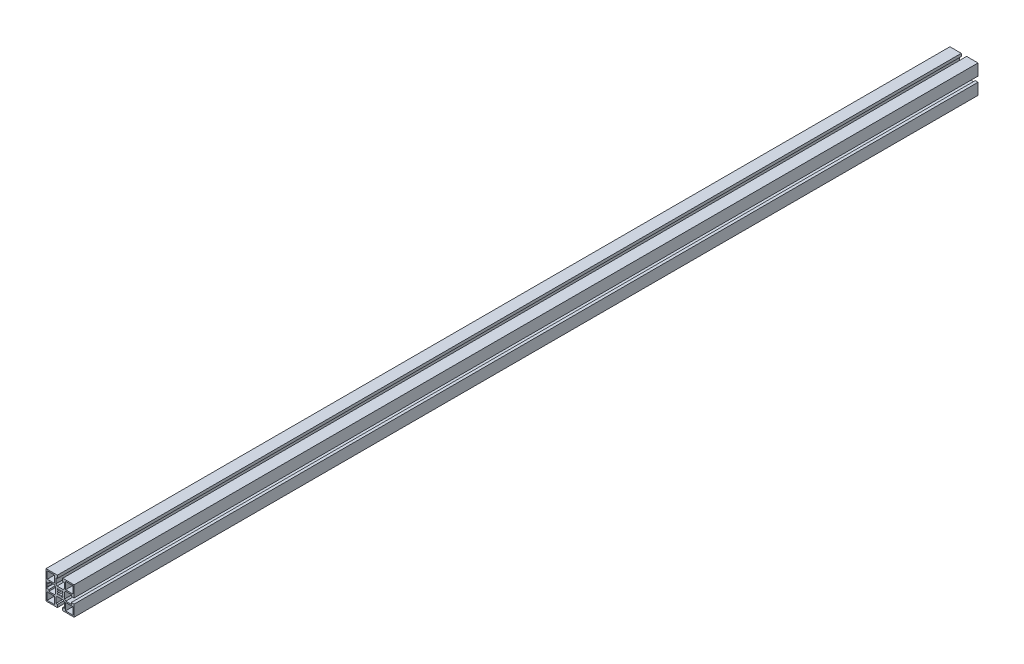
from build123d import *

# Parameters (mm, degrees)
SKETCH1_W           = 11.699975178
SKETCH1_H           = 11.699996949
SKETCH1_W_2         = 11.699990436
SKETCH1_H_2         = 11.699981689
SKETCH1_W_3         = 11.699990437
SKETCH1_H_3         = 11.699975177
SKETCH1_W_4         = 11.699981689
SKETCH1_H_4         = 11.699990436
BOSS_EXTRUDE1_DEPTH = 1447.8
CUT_EXTRUDE1_REACH  = 1450.15


with BuildPart() as part:
    # Sketch1 → Boss-Extrude1 (new body)
    with BuildSketch(Plane.XY):
        Polygon((22.500515052, 22.499297556), (-22.499484399, 22.499298105), (-22.499484948, -22.500701346), (-4.249491942, -22.500701568), (-4.249491942, -22.200733242), (-4.24949208, -18.000719999), (-6.799479919, -18.000719999), (-6.799480207, -9.200732353), (-4.799480391, -7.200732362), (4.800525817, -7.200732047), (6.8005258, -9.200731855), (6.800526088, -18.000720263), (4.250507877, -18.000720263), (4.250508015, -22.200733153), (4.250508015, -22.500701672), (22.500514502, -22.500701895), (22.500514725, -4.250714302), (22.200520351, -4.250714302), (18.000507108, -4.25071444), (18.000507108, -6.800702279), (9.200519462, -6.800702567), (7.200519471, -4.800702751), (7.200519156, 4.799303458), (9.200518964, 6.79930344), (18.000507424, 6.799303729), (18.000507424, 4.249285514), (22.200520261, 4.249285652), (22.500514829, 4.249285652), align=None)
        with BuildLine():
            Line((-4.249491247, 17.999291576), (-4.249490956, 22.199304807))
            Line((-4.249490956, 22.199304807), (-3.949472548, 22.199304807))
            Line((-3.949472548, 22.199304807), (-3.481695222, 21.73152644))
            ThreePointArc((-3.481695222, 21.73152644), (-2.670636178, 21.189593132), (-1.713926324, 20.999291428))
            Line((-1.713926324, 20.999291428), (1.714975167, 20.999291428))
            ThreePointArc((1.714975167, 20.999291428), (2.671722509, 21.189608628), (3.482801459, 21.731583767))
            Line((3.482801459, 21.731583767), (3.950490798, 22.199304487))
            Line((3.950490798, 22.199304487), (4.250509108, 22.199304487))
            Line((4.250509108, 22.199304487), (4.250508817, 17.999291575))
            Line((4.250508817, 17.999291575), (6.800527063, 17.999291575))
            Line((6.800527063, 17.999291575), (6.800526453, 9.199302988))
            Line((6.800526453, 9.199302988), (4.800526064, 7.199302969))
            Line((4.800526064, 7.199302969), (-4.799479817, 7.199303635))
            Line((-4.799479817, 7.199303635), (-6.799479854, 9.199304042))
            Line((-6.799479854, 9.199304042), (-6.799479244, 17.999291576))
            Line((-6.799479244, 17.999291576), (-4.249491247, 17.999291576))
        make_face(mode=Mode.SUBTRACT)
        with BuildLine():
            Line((-17.99949762, -4.250714253), (-22.199510799, -4.250714391))
            Line((-22.199510799, -4.250714391), (-22.199510799, -3.950696126))
            Line((-22.199510799, -3.950696126), (-21.731790056, -3.48300681))
            ThreePointArc((-21.731790056, -3.48300681), (-21.189814855, -2.671927844), (-20.999497617, -1.71518046))
            Line((-20.999497617, -1.71518046), (-20.999497617, 1.713721031))
            ThreePointArc((-20.999497617, 1.713721031), (-21.189799286, 2.670430863), (-21.731732544, 3.481489907))
            Line((-21.731732544, 3.481489907), (-22.199510888, 3.949267256))
            Line((-22.199510888, 3.949267256), (-22.199510888, 4.249285566))
            Line((-22.199510888, 4.249285566), (-17.999497356, 4.249285704))
            Line((-17.999497356, 4.249285704), (-17.999497356, 6.79927354))
            Line((-17.999497356, 6.79927354), (-9.199509947, 6.799273828))
            Line((-9.199509947, 6.799273828), (-7.199509956, 4.799274012))
            Line((-7.199509956, 4.799274012), (-7.199509641, -4.800732197))
            Line((-7.199509641, -4.800732197), (-9.199509449, -6.800732179))
            Line((-9.199509449, -6.800732179), (-17.99949762, -6.800732468))
            Line((-17.99949762, -6.800732468), (-17.99949762, -4.250714253))
        make_face(mode=Mode.SUBTRACT)
        with Locations((-14.649542346, -14.650709384)):
            Rectangle(SKETCH1_W, SKETCH1_H, mode=Mode.SUBTRACT)
        with Locations((14.65050626, -14.650767962)):
            Rectangle(SKETCH1_W_2, SKETCH1_H_2, mode=Mode.SUBTRACT)
        with BuildLine():
            Line((-3.181457266, -4.596908447), (-4.595670829, -3.182694885))
            Line((-4.595670829, -3.182694885), (-3.26221457, -1.849238626))
            ThreePointArc((-3.26221457, -1.849238626), (-3.749476751, -0.00071437), (-3.26221457, 1.847809887))
            Line((-3.26221457, 1.847809887), (-4.595670829, 3.181266146))
            Line((-4.595670829, 3.181266146), (-3.181457266, 4.595479708))
            Line((-3.181457266, 4.595479708), (-1.848001007, 3.262023449))
            ThreePointArc((-1.848001007, 3.262023449), (0.000523249, 3.74928563), (1.849047505, 3.262023449))
            Line((1.849047505, 3.262023449), (3.182503764, 4.595479708))
            Line((3.182503764, 4.595479708), (4.596717327, 3.181266146))
            Line((4.596717327, 3.181266146), (3.263261068, 1.847809887))
            ThreePointArc((3.263261068, 1.847809887), (3.750523249, -0.00071437), (3.263261068, -1.849238626))
            Line((3.263261068, -1.849238626), (4.596717327, -3.182694885))
            Line((4.596717327, -3.182694885), (3.182503764, -4.596908447))
            Line((3.182503764, -4.596908447), (1.849047505, -3.263452188))
            ThreePointArc((1.849047505, -3.263452188), (0.000523249, -3.75071437), (-1.848001007, -3.263452188))
            Line((-1.848001007, -3.263452188), (-3.181457266, -4.596908447))
        make_face(mode=Mode.SUBTRACT)
        with Locations((-14.64949028, 14.649335967)):
            Rectangle(SKETCH1_W_3, SKETCH1_H_3, mode=Mode.SUBTRACT)
        with Locations((14.650561583, 14.6492839)):
            Rectangle(SKETCH1_W_4, SKETCH1_H_4, mode=Mode.SUBTRACT)
    extrude(amount=BOSS_EXTRUDE1_DEPTH)

    # Sketch1_4 → Cut-Extrude1 (cut, up to next)
    with BuildSketch(Plane.XY, mode=Mode.PRIVATE) as cut_extrude1_sk1:
        with BuildLine():
            Line((-4.249490956, 22.499297883), (-4.249490956, 22.199304807))
            Line((-4.249490956, 22.199304807), (-3.949472548, 22.199304807))
            Line((-3.949472548, 22.199304807), (-3.481695222, 21.73152644))
            ThreePointArc((-3.481695222, 21.73152644), (-2.670636178, 21.189593132), (-1.713926324, 20.999291428))
            Line((-1.713926324, 20.999291428), (1.714975167, 20.999291428))
            ThreePointArc((1.714975167, 20.999291428), (2.671722509, 21.189608628), (3.482801459, 21.731583767))
            Line((3.482801459, 21.731583767), (3.950490798, 22.199304487))
            Line((3.950490798, 22.199304487), (4.250509108, 22.199304487))
            Line((4.250509108, 22.199304487), (4.250509108, 22.499297779))
            Line((4.250509108, 22.499297779), (-4.249490956, 22.499297883))
        make_face()
    cut_extrude1_tool1 = extrude(cut_extrude1_sk1.sketch, amount=CUT_EXTRUDE1_REACH, mode=Mode.PRIVATE) & part.part
    add(cut_extrude1_tool1.solids().sort_by_distance((0.000518, 21.824215, 0))[0], mode=Mode.SUBTRACT)


solid = part.part
